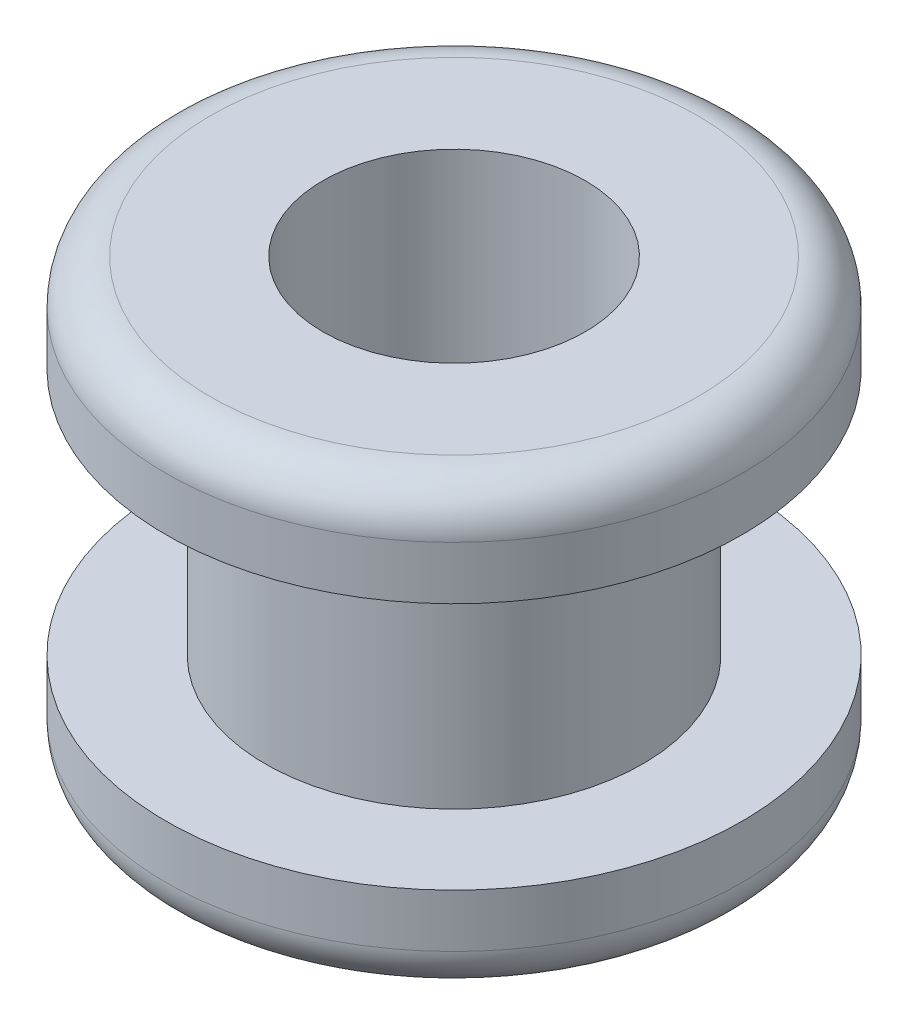
from build123d import *


with BuildPart() as part:
    # Esquisse1 → Révolution1 (revolve)
    with BuildSketch(Plane.XY):
        with BuildLine():
            Line((-3.25, -1.4), (-3.25, -2))
            ThreePointArc((-3.25, -2), (-3.103553391, -2.353553391), (-2.75, -2.5))
            Line((-2.75, -2.5), (-1.48, -2.5))
            Line((-1.48, -2.5), (-1.48, 2.5))
            Line((-1.48, 2.5), (-2.75, 2.5))
            ThreePointArc((-2.75, 2.5), (-3.103553391, 2.353553391), (-3.25, 2))
            Line((-3.25, 2), (-3.25, 1.4))
            Line((-3.25, 1.4), (-2.13, 1.4))
            Line((-2.13, 1.4), (-2.13, -1.4))
            Line((-2.13, -1.4), (-3.25, -1.4))
        make_face()
    revolve(axis=Axis((0, 0, 0), (0, 1, 0)))


solid = part.part
